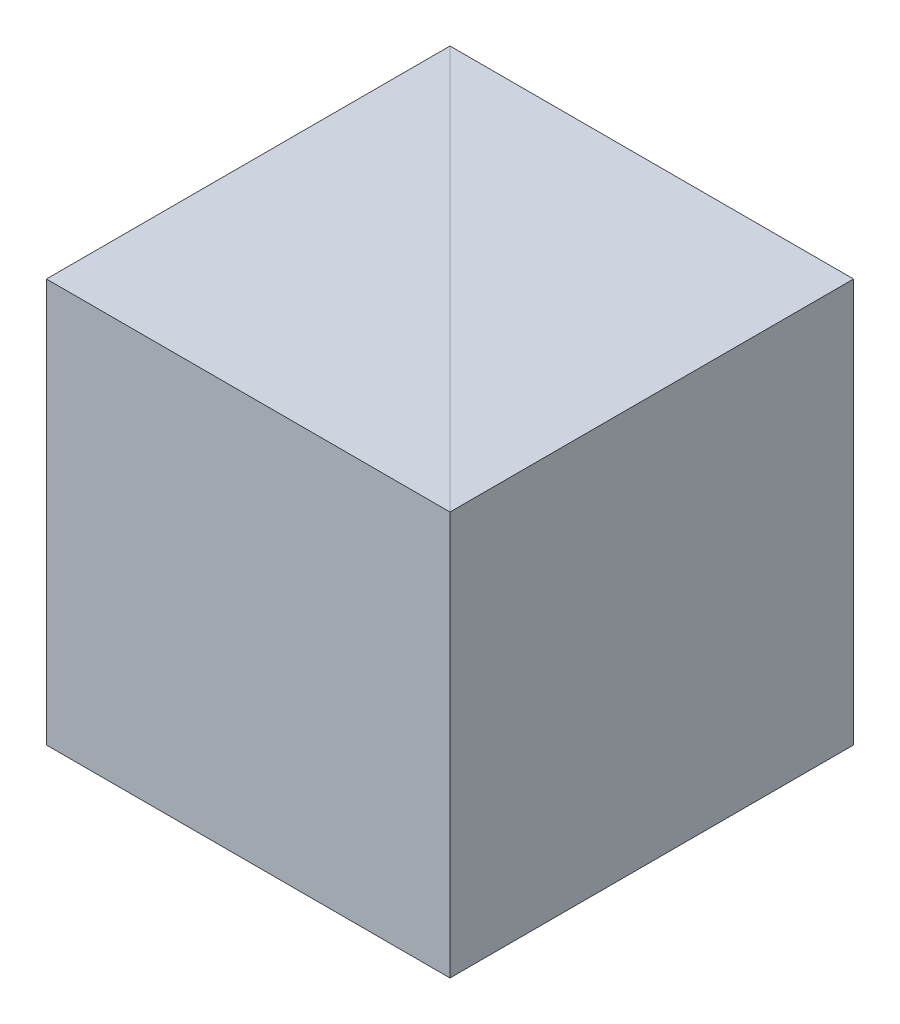
from build123d import *

# Parameters (mm, degrees)
EXTRUDE_1_DEPTH = 15
EXTRUDE_2_DEPTH = 15


with BuildPart() as part:
    # 草图1 → 凸台-拉伸1 (new body)
    with BuildSketch(Plane(origin=(0, 0, 0), x_dir=(1, 0, 0), z_dir=(0, 1, 0))):
        Polygon((0, 0), (0, 15), (-15, 15), align=None)
    extrude(amount=EXTRUDE_1_DEPTH)


with BuildPart() as body_2:
    # 草图2 → 凸台-拉伸2 (new body)
    with BuildSketch(Plane.XZ):
        Polygon((-15, -15), (-15, 0), (0, 0), align=None)
    extrude(amount=-EXTRUDE_2_DEPTH)


solid = Compound([part.part, body_2.part])
